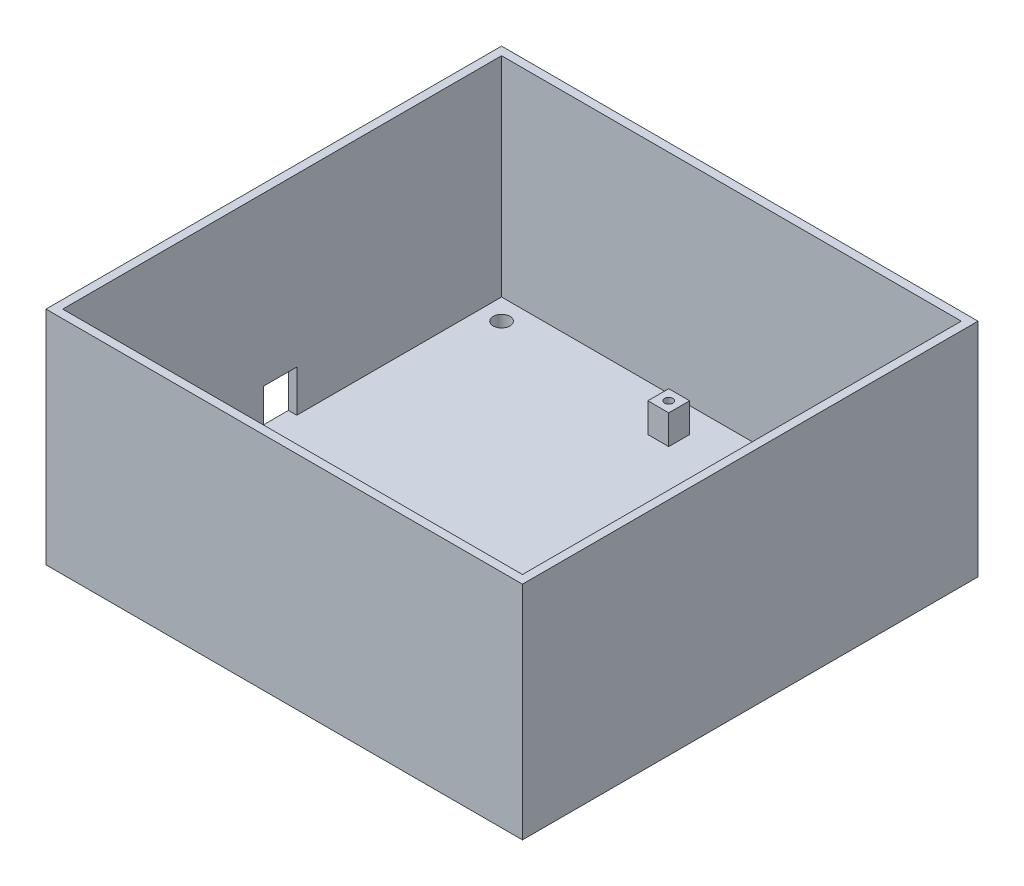
from build123d import *

# Parameters (mm, degrees)
SKETCH1_W           = 114
SKETCH1_H           = 104
BOSS_EXTRUDE1_DEPTH = 3
SKETCH2_W           = 114
SKETCH2_H           = 104
SKETCH2_W_2         = 110
SKETCH2_H_2         = 100
BOSS_EXTRUDE2_DEPTH = 50
SKETCH3_W           = 5
SKETCH3_H           = 5
BOSS_EXTRUDE4_DEPTH = 7
SKETCH8_W           = 114
SKETCH8_H           = 53
BOSS_EXTRUDE6_DEPTH = 5
SKETCH9_W           = 110
SKETCH9_H           = 50
CUT_EXTRUDE2_DEPTH  = 5
SKETCH12_W          = 8
SKETCH12_H          = 10
CUT_EXTRUDE3_DEPTH  = 2
SKETCH14_R          = 1
CUT_EXTRUDE5_DEPTH  = 3
SKETCH15_R          = 2
CUT_EXTRUDE6_DEPTH  = 3


with BuildPart() as part:
    # Sketch1 → Boss-Extrude1 (new body)
    with BuildSketch(Plane(origin=(0, 0, 0), x_dir=(1, 0, 0), z_dir=(0, 1, 0))):
        Rectangle(SKETCH1_W, SKETCH1_H)
    extrude(amount=BOSS_EXTRUDE1_DEPTH)

    # Sketch2 → Boss-Extrude2 (add)
    with BuildSketch(Plane(origin=(0, 3, 0), x_dir=(1, 0, 0), z_dir=(0, 1, 0))):
        Rectangle(SKETCH2_W, SKETCH2_H)
        Rectangle(SKETCH2_W_2, SKETCH2_H_2, mode=Mode.SUBTRACT)
    extrude(amount=BOSS_EXTRUDE2_DEPTH)

    # Sketch3 → Boss-Extrude4 (add)
    with BuildSketch(Plane(origin=(0, 3, 0), x_dir=(1, 0, 0), z_dir=(0, 1, 0))):
        with Locations((-6.5, 41.5)):
            Rectangle(SKETCH3_W, SKETCH3_H)
        with Locations((52.5, 46.5)):
            Rectangle(SKETCH3_W, SKETCH3_H)
        with Locations((-6.5, -41.5)):
            Rectangle(SKETCH3_W, SKETCH3_H)
        with Locations((37.5, -41.5)):
            Rectangle(SKETCH3_W, SKETCH3_H)
    extrude(amount=BOSS_EXTRUDE4_DEPTH)

    # Sketch8 → Boss-Extrude6 (add)
    with BuildSketch(Plane.XY.offset(52)):
        with Locations((0, 26.5)):
            Rectangle(SKETCH8_W, SKETCH8_H)
    extrude(amount=BOSS_EXTRUDE6_DEPTH)

    # Sketch9 → Cut-Extrude2 (cut)
    with BuildSketch(Plane(origin=(0, 0, 50), x_dir=(-1, 0, 0), z_dir=(0, 0, -1))):
        with Locations((0, 28)):
            Rectangle(SKETCH9_W, SKETCH9_H)
    extrude(amount=-CUT_EXTRUDE2_DEPTH, mode=Mode.SUBTRACT)

    # Sketch12 → Cut-Extrude3 (cut)
    with BuildSketch(Plane(origin=(-55, 0, 0), x_dir=(0, 0, -1), z_dir=(1, 0, 0))):
        with Locations((-3, 8)):
            Rectangle(SKETCH12_W, SKETCH12_H)
    extrude(amount=-CUT_EXTRUDE3_DEPTH, mode=Mode.SUBTRACT)

    # Sketch14 → Cut-Extrude5 (cut)
    with BuildSketch(Plane(origin=(0, 10, 0), x_dir=(1, 0, 0), z_dir=(0, 1, 0))):
        with Locations((-6.5, 41.5)):
            Circle(SKETCH14_R)
        with Locations((-6.5, -41.5)):
            Circle(SKETCH14_R)
        with Locations((37.5, -41.5)):
            Circle(SKETCH14_R)
        with Locations((52.5, 46.5)):
            Circle(SKETCH14_R)
    extrude(amount=-CUT_EXTRUDE5_DEPTH, mode=Mode.SUBTRACT)

    # Sketch15 → Cut-Extrude6 (cut)
    with BuildSketch(Plane(origin=(0, 3, 0), x_dir=(1, 0, 0), z_dir=(0, 1, 0))):
        with Locations((-50, 45)):
            Circle(SKETCH15_R)
        with Locations((-50, -50)):
            Circle(SKETCH15_R)
        with Locations((43.810047303, -50)):
            Circle(SKETCH15_R)
        with Locations((43.810047303, 45)):
            Circle(SKETCH15_R)
    extrude(amount=-CUT_EXTRUDE6_DEPTH, mode=Mode.SUBTRACT)


solid = part.part
